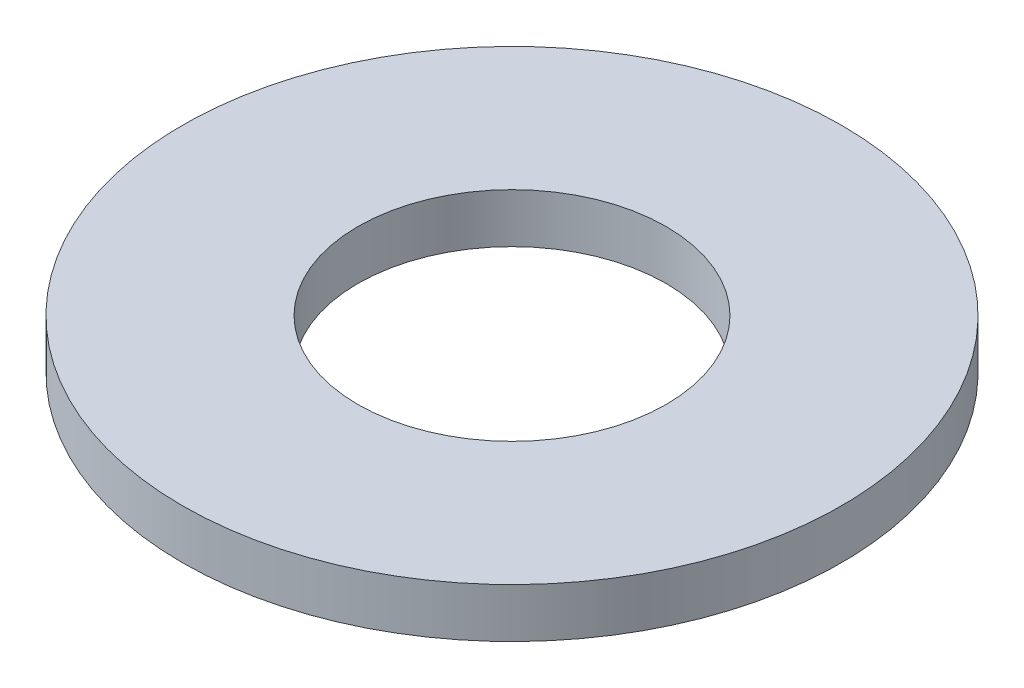
from build123d import *

# Parameters (mm, degrees)
SKETCH1_R           = 5.5118
SKETCH1_R_2         = 2.5781
BOSS_EXTRUDE1_DEPTH = 0.8255


with BuildPart() as part:
    # Sketch1 → Boss-Extrude1 (new body)
    with BuildSketch(Plane(origin=(0, 0, 0), x_dir=(1, 0, 0), z_dir=(0, 1, 0))):
        Circle(SKETCH1_R)
        Circle(SKETCH1_R_2, mode=Mode.SUBTRACT)
    extrude(amount=BOSS_EXTRUDE1_DEPTH)


solid = part.part
